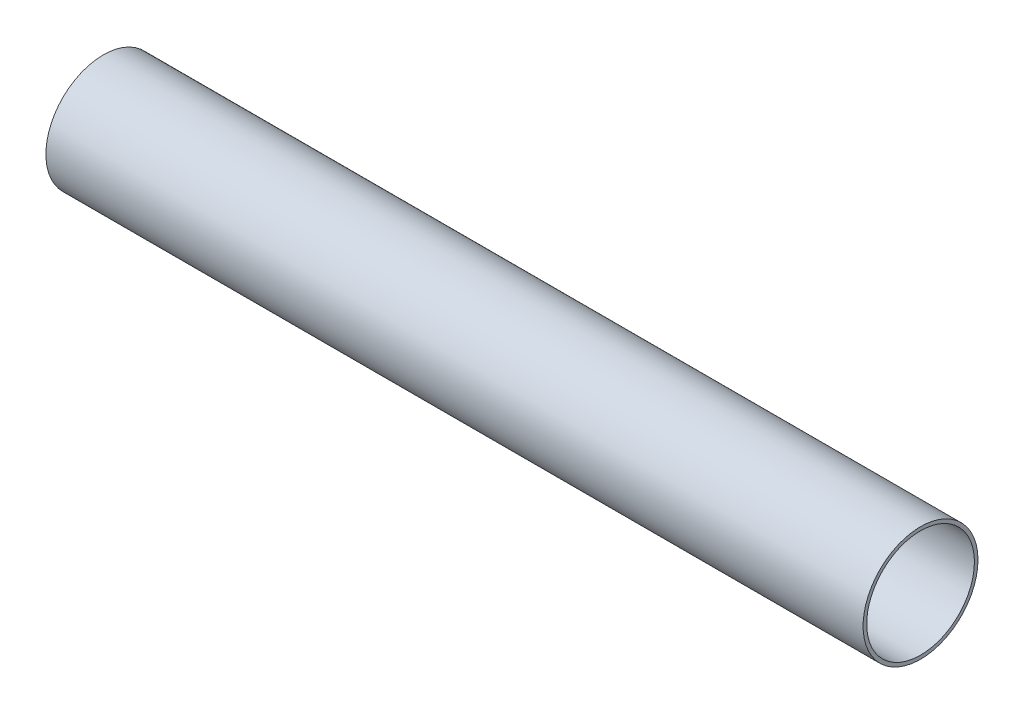
from build123d import *

# Parameters (mm, degrees)
SKETCH1_R      = 14.2875
SKETCH1_R_2    = 13.3985
EXTRUDE1_DEPTH = 101.6


with BuildPart() as part:
    # Sketch1 → Extrude1 (new body, symmetric)
    with BuildSketch(Plane(origin=(0, 0, 0), x_dir=(0, 0, -1), z_dir=(1, 0, 0))):
        Circle(SKETCH1_R)
        Circle(SKETCH1_R_2, mode=Mode.SUBTRACT)
    extrude(amount=EXTRUDE1_DEPTH, both=True)


solid = part.part
